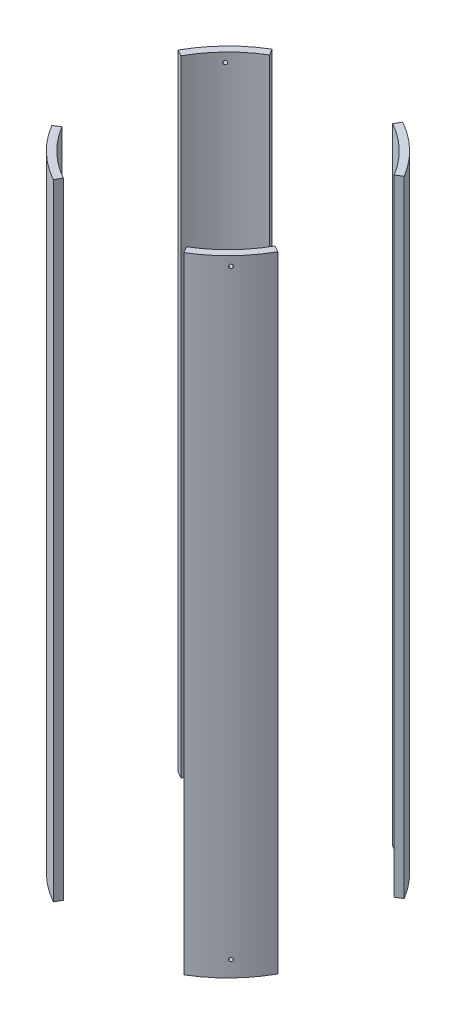
from build123d import *

# Parameters (mm, degrees)
SKETCH2_R               = 88.9
SKETCH2_R_2             = 83.82
BOSS_EXTRUDE1_DEPTH     = 216.4715
CUT_EXTRUDE1_DEPTH      = 217.4715
CUT_EXTRUDE1_DEPTH_BACK = 217.4715
SKETCH5_R               = 1.27
BOLT_HOLES_DEPTH        = 29.911624556
BOLT_PATTERN_COUNT      = 4


with BuildPart() as part:
    # Sketch2 → Boss-Extrude1 (new body, symmetric)
    with BuildSketch(Plane(origin=(0, 0, 0), x_dir=(1, 0, 0), z_dir=(0, 1, 0))):
        Circle(SKETCH2_R)
        Circle(SKETCH2_R_2, mode=Mode.SUBTRACT)
    extrude(amount=BOSS_EXTRUDE1_DEPTH, both=True)

    # Sketch3 → Cut-Extrude1 (cut, two sides)
    with BuildSketch(Plane(origin=(0, 0, 0), x_dir=(1, 0, 0), z_dir=(0, 1, 0))) as cut_extrude1_sk:
        Polygon((169.661755759, -94.300371224), (0, 0), (169.661755759, 101.677593364), align=None)
        Polygon((0, 0), (53.900027233, 96.974944394), (-58.116685864, 96.974944394), align=None)
        Polygon((-123.741299607, 68.777140945), (-123.741299607, -74.157652604), (0, 0), align=None)
        Polygon((-65.840936026, -118.45858783), (0, 0), (70.991745134, -118.45858783), align=None)
    extrude(amount=CUT_EXTRUDE1_DEPTH, mode=Mode.SUBTRACT)
    extrude(cut_extrude1_sk.sketch, amount=-CUT_EXTRUDE1_DEPTH_BACK, mode=Mode.SUBTRACT)

    # Sketch5 → Bolt holes (cut, through all)
    with BuildSketch(Plane(origin=(-56.309218645, 0, 58.175814955), x_dir=(-0.718540152, 0, -0.695485478), z_dir=(0.695485478, 0, -0.718540152))):
        with Locations((-0.02278764, 210.1215)):
            Circle(SKETCH5_R)
        with Locations((-0.02278764, -205.359)):
            Circle(SKETCH5_R)
    bolt_holes = extrude(amount=-BOLT_HOLES_DEPTH, mode=Mode.SUBTRACT)

    # Bolt pattern: Bolt holes ×4 about axis
    bolt_pattern_axis = Axis((0, 216.4715, 0), (0, 1, 0))
    for i in range(1, BOLT_PATTERN_COUNT):
        add(bolt_holes.rotate(bolt_pattern_axis, i * 360 / BOLT_PATTERN_COUNT), mode=Mode.SUBTRACT)


solid = part.part
